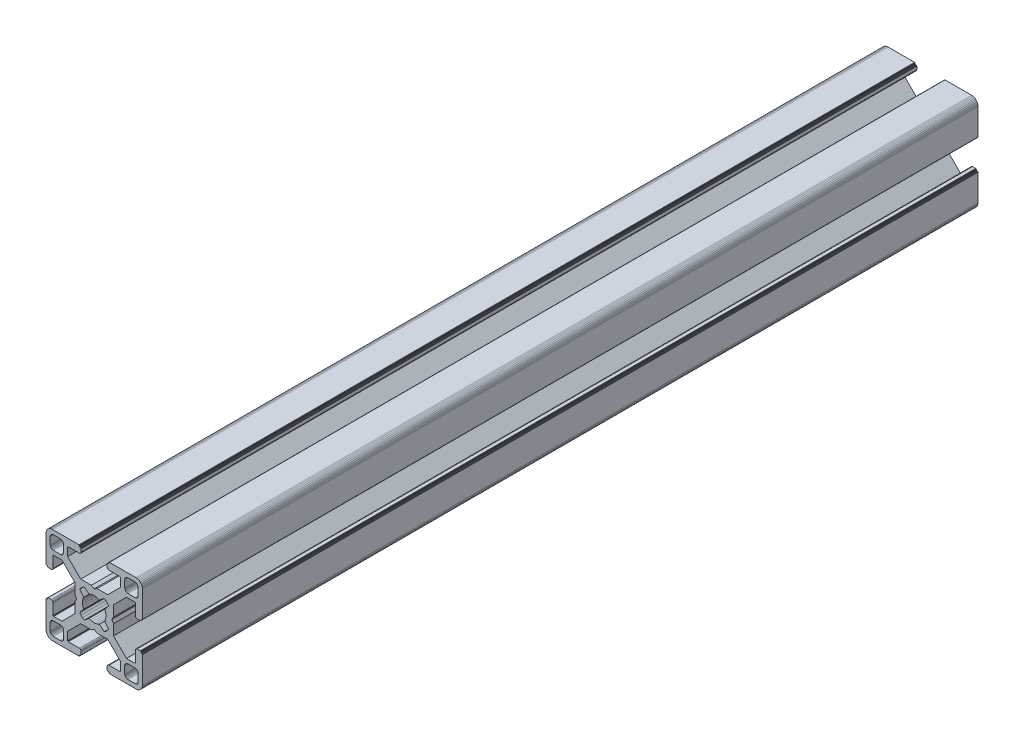
from build123d import *

# Parameters (mm, degrees)
BOSS_EXTRUDE1_DEPTH = 260


with BuildPart() as part:
    # Sketch1 → Boss-Extrude1 (new body)
    with BuildSketch(Plane.XY):
        Polygon((28.34729664, 29.969613999), (28.000000864, 29.999999329), (19.750000909, 29.999999329), (19.715268165, 29.996961355), (19.681595266, 29.987938702), (19.649999216, 29.973205179), (19.621443003, 29.953207821), (19.596790895, 29.928557575), (19.576793537, 29.899999499), (19.562061876, 29.868405312), (19.55303736, 29.834728688), (19.549999386, 29.799999669), (19.549999386, 29.699999839), (19.546961412, 29.665268958), (19.537936896, 29.631596059), (19.523203373, 29.599998146), (19.503207877, 29.571441934), (19.478557631, 29.546789825), (19.449999556, 29.526794329), (19.418403506, 29.512060806), (19.384728745, 29.503038153), (19.349999726, 29.500000179), (19.249999896, 29.500000179), (19.215267517, 29.496958527), (19.181592755, 29.487935874), (19.149996706, 29.47320235), (19.12143863, 29.453206855), (19.096788384, 29.428554746), (19.076791026, 29.399996671), (19.062057503, 29.368402484), (19.05303485, 29.334725859), (19.049996876, 29.299998703), (19.049996876, 28.39999837), (19.059110798, 28.29580945), (19.08618062, 28.194785165), (19.13038119, 28.099997016), (19.190369539, 28.014324653), (19.264324002, 27.94037019), (19.349996366, 27.88038184), (19.444784515, 27.836181271), (19.545806937, 27.809111449), (19.650010894, 27.799984574), (23.050010706, 27.799984574), (23.084741588, 27.7969466), (23.118414487, 27.787923946), (23.150012399, 27.773190423), (23.178568612, 27.753193065), (23.203220721, 27.728542819), (23.223218079, 27.699984744), (23.237949739, 27.668386831), (23.246974255, 27.634713932), (23.25001142, 27.59998608), (23.25001142, 25.049987618), (19.204474482, 20.999982084), (15.900007876, 20.999982084), (15.000008474, 20.48483404), (14.10000814, 20.999982084), (10.795543398, 20.999982084), (7.997342887, 23.801274731), (6.750011387, 25.049984589), (6.750011387, 27.599983051), (6.753049362, 27.634713932), (6.762072946, 27.668386831), (6.776805538, 27.699984744), (6.796801965, 27.728542819), (6.821454073, 27.753193065), (6.850011218, 27.773190423), (6.881607267, 27.787923946), (6.915282029, 27.7969466), (6.950011048, 27.799984574), (10.350011791, 27.799984574), (10.45420071, 27.809098497), (10.555223133, 27.836168318), (10.650011282, 27.880368888), (10.735683645, 27.940357238), (10.809638108, 28.014311701), (10.869626458, 28.099984064), (10.913827027, 28.194772213), (10.940895918, 28.295796498), (10.950010772, 28.399985417), (10.950010772, 29.299985751), (10.946974575, 29.334739239), (10.93795065, 29.368415522), (10.923215933, 29.400009153), (10.903218427, 29.428566473), (10.878566319, 29.45321765), (10.849999264, 29.473204166), (10.818403214, 29.487937689), (10.784728453, 29.496960342), (10.749999434, 29.500000179), (10.649999604, 29.500000179), (10.615270585, 29.503038153), (10.581595823, 29.512060806), (10.549999774, 29.526794329), (10.521441698, 29.546789825), (10.496791452, 29.571441934), (10.476795025, 29.599998146), (10.462061502, 29.631596059), (10.453037918, 29.665268958), (10.449999943, 29.699999839), (10.449999943, 29.799999669), (10.446961969, 29.834728688), (10.437938385, 29.868405312), (10.423205793, 29.899999499), (10.403208435, 29.928557575), (10.378557257, 29.953207821), (10.350000113, 29.973205179), (10.318404064, 29.987938702), (10.284729302, 29.996961355), (10.250000283, 29.999999329), (1.999999397, 29.999999329), (1.652702689, 29.969613999), (1.315958682, 29.879383743), (0.999999233, 29.732050374), (0.714424066, 29.532089829), (0.467910431, 29.285576195), (0.267948955, 28.999999166), (0.120614655, 28.684040532), (0.030384399, 28.34729664), (0, 28.000000864), (0, 19.750000909), (0.003037974, 19.715268165), (0.012061559, 19.681595266), (0.026795082, 19.649999216), (0.046790577, 19.621441141), (0.071442686, 19.596789032), (0.09999983, 19.576793537), (0.13159588, 19.562060013), (0.165270641, 19.55303736), (0.19999966, 19.549999386), (0.299999461, 19.549999386), (0.334728509, 19.546959549), (0.368403242, 19.537936896), (0.399999321, 19.523203373), (0.428556465, 19.503207877), (0.453208573, 19.478555769), (0.473204069, 19.449997693), (0.487937592, 19.418403506), (0.496961176, 19.384728745), (0.499999151, 19.349999726), (0.499999151, 19.249998033), (0.503038056, 19.215269014), (0.512060709, 19.181594253), (0.526794232, 19.150000066), (0.546790194, 19.121441524), (0.571441837, 19.096789882), (0.60000029, 19.076794925), (0.631595686, 19.062061999), (0.665270619, 19.053039982), (0.700000626, 19.050000801), (1.60000096, 19.050000801), (1.704189879, 19.059116587), (1.805213233, 19.086186409), (1.90000045, 19.130385115), (1.985673745, 19.190375328), (2.059627277, 19.264327928), (2.119616325, 19.350002154), (2.163816196, 19.444788441), (2.190886018, 19.545812726), (2.200000872, 19.650001645), (2.200000872, 23.050001457), (2.203039777, 23.084732338), (2.212062431, 23.118405237), (2.226795954, 23.15000315), (2.246792381, 23.178559362), (2.271443558, 23.203211471), (2.300000702, 23.223206967), (2.331596752, 23.23794049), (2.365271513, 23.246965006), (2.400001464, 23.250001117), (4.950000857, 23.250001117), (7.997332093, 20.202670812), (8.995535423, 19.204467788), (8.995535423, 15.900001182), (9.515148227, 15.00000178), (8.995535423, 14.100002378), (8.995535423, 10.795536704), (4.950000857, 6.750002138), (2.400001464, 6.750002138), (2.365271513, 6.753040112), (2.331596752, 6.762063697), (2.300000702, 6.77679722), (2.271443558, 6.796793647), (2.246792381, 6.821444824), (2.226795954, 6.850001968), (2.212062431, 6.881598018), (2.203039777, 6.915272779), (2.200000872, 6.950002729), (2.200000872, 10.350002542), (2.190896812, 10.454174265), (2.16382699, 10.555197618), (2.119627119, 10.649984836), (2.059638071, 10.735658131), (1.985684539, 10.809611663), (1.900011244, 10.869600944), (1.805224027, 10.913800582), (1.704200673, 10.940870404), (1.600011754, 10.949986189), (0.70001142, 10.949986189), (0.665281355, 10.946948596), (0.631606253, 10.937926283), (0.600010578, 10.923193954), (0.571451747, 10.903199537), (0.546799638, 10.87854836), (0.526794232, 10.850000195), (0.512060709, 10.818404146), (0.503038056, 10.784730315), (0.499999151, 10.750000365), (0.499999151, 10.650000535), (0.496961176, 10.615270585), (0.487937592, 10.581596754), (0.473204069, 10.550000705), (0.453208573, 10.521443561), (0.428556465, 10.496791452), (0.399999321, 10.476795956), (0.368403242, 10.462062433), (0.334728509, 10.453038849), (0.299999461, 10.449999943), (0.19999966, 10.449999943), (0.165270641, 10.446961969), (0.13159588, 10.437939316), (0.09999983, 10.423205793), (0.071442686, 10.403209366), (0.046790577, 10.378558189), (0.026795082, 10.350000113), (0.012061559, 10.318404064), (0.003037974, 10.284729302), (0, 10.250000283), (0, 1.999999397), (0.030384399, 1.652702689), (0.120614655, 1.315958682), (0.267948955, 0.999999233), (0.467910431, 0.714424066), (0.714424066, 0.467910431), (0.999999233, 0.267948955), (1.315958682, 0.120614655), (1.652702689, 0.030384399), (1.999999397, 0), (10.250000283, 0), (10.284729302, 0.003037974), (10.318404064, 0.012061559), (10.350000113, 0.026795082), (10.378557257, 0.046790577), (10.403208435, 0.071442686), (10.423205793, 0.09999983), (10.437938385, 0.13159588), (10.446961969, 0.165270641), (10.449999943, 0.19999966), (10.449999943, 0.300000422), (10.453037918, 0.334729441), (10.462061502, 0.368404202), (10.476795025, 0.400000252), (10.496791452, 0.428557396), (10.521441698, 0.453208573), (10.549999774, 0.473205), (10.581595823, 0.487938523), (10.615270585, 0.496961176), (10.649999604, 0.500000082), (10.749999434, 0.500000082), (10.784728453, 0.503038056), (10.818403214, 0.512060709), (10.849999264, 0.526794232), (10.878547894, 0.546800104), (10.903198606, 0.571451747), (10.923194493, 0.6000102), (10.93792742, 0.631606528), (10.946949437, 0.66528146), (10.950010772, 0.699984975), (10.950010772, 1.599985308), (10.940895918, 1.704174228), (10.913827027, 1.805197581), (10.869626458, 1.89998573), (10.809638108, 1.985658094), (10.735683645, 2.059612557), (10.650011282, 2.119600674), (10.555223133, 2.163801476), (10.45420071, 2.190870367), (10.350011791, 2.199985221), (6.950011048, 2.199985221), (6.915282029, 2.203024126), (6.881607267, 2.212046779), (6.850011218, 2.226780302), (6.821454073, 2.246776729), (6.796801965, 2.271427907), (6.776805538, 2.299985982), (6.762072946, 2.331582032), (6.753049362, 2.365256793), (6.750011387, 2.399985812), (6.750011387, 4.949985206), (9.787457566, 7.990785077), (10.795545277, 8.999985833), (14.100010019, 8.999985833), (15.000010353, 9.515133877), (15.900009756, 8.999985833), (19.204476361, 8.999985833), (20.21256413, 7.990786065), (23.25001142, 4.949988235), (23.25001142, 2.399988841), (23.246974255, 2.365256793), (23.237949739, 2.331582032), (23.223218079, 2.299985982), (23.203220721, 2.271427907), (23.178568612, 2.246776729), (23.150012399, 2.226780302), (23.118414487, 2.212046779), (23.084741588, 2.203024126), (23.050010706, 2.199985221), (19.650010894, 2.199985221), (19.545806937, 2.190883319), (19.444784515, 2.163814428), (19.349996366, 2.119613626), (19.264324002, 2.059625509), (19.190369539, 1.985671046), (19.13038119, 1.899998682), (19.08618062, 1.805210533), (19.059110798, 1.70418718), (19.049996876, 1.599998261), (19.049996876, 0.699997927), (19.053035506, 0.665268966), (19.062058795, 0.631594374), (19.076792915, 0.599998603), (19.096790813, 0.571440905), (19.121441524, 0.546790194), (19.149999978, 0.526794306), (19.181596306, 0.51206138), (19.215271238, 0.503039363), (19.249999896, 0.500000082), (19.349999726, 0.500000082), (19.384728745, 0.496961176), (19.418403506, 0.487938523), (19.449999556, 0.473205), (19.478557631, 0.453208573), (19.503207877, 0.428557396), (19.523203373, 0.400000252), (19.537936896, 0.368404202), (19.546961412, 0.334729441), (19.549999386, 0.300000422), (19.549999386, 0.19999966), (19.55303736, 0.165270641), (19.562061876, 0.13159588), (19.576793537, 0.09999983), (19.596789964, 0.071441755), (19.621442072, 0.046789646), (19.649998285, 0.02679415), (19.681594335, 0.012060627), (19.715267234, 0.003037043), (19.750000909, 0), (28.000000864, 0), (28.34729664, 0.030384399), (28.684040532, 0.120614655), (28.999999166, 0.267948955), (29.285576195, 0.467910431), (29.532089829, 0.714424066), (29.732050374, 0.999999233), (29.879383743, 1.315958682), (29.969613999, 1.652702689), (29.999999329, 1.999999397), (29.999999329, 10.250000283), (29.996974806, 10.284715361), (29.987951516, 10.318389952), (29.973217396, 10.349985723), (29.953219499, 10.378543421), (29.928568787, 10.403194133), (29.899999499, 10.423205793), (29.868405312, 10.437939316), (29.834728688, 10.446961969), (29.799999669, 10.449999943), (29.699999839, 10.449999943), (29.664909937, 10.453400043), (29.631233313, 10.462423628), (29.599637263, 10.477157151), (29.57108105, 10.497152646), (29.546427079, 10.521804755), (29.526433446, 10.550361899), (29.511699923, 10.581957949), (29.502675407, 10.615631779), (29.499637433, 10.650361729), (29.499637433, 10.750361559), (29.49697202, 10.784715548), (29.487949367, 10.818389378), (29.473215844, 10.849985428), (29.453220348, 10.878542572), (29.428568239, 10.90319468), (29.400010164, 10.923190176), (29.368415977, 10.937923699), (29.334741215, 10.946947284), (29.300012197, 10.949986189), (28.400011863, 10.949986189), (28.29581215, 10.9408876), (28.194787865, 10.913817778), (28.099999716, 10.86961814), (28.014327352, 10.809628859), (27.940374752, 10.735675327), (27.880384539, 10.650002032), (27.836185833, 10.555214814), (27.809114148, 10.454191461), (27.800000225, 10.350002542), (27.800000225, 6.950002729), (27.796962251, 6.915272779), (27.787939598, 6.881598018), (27.773206075, 6.850001968), (27.753208716, 6.821444824), (27.728558471, 6.796793647), (27.700000395, 6.77679722), (27.668404345, 6.762063697), (27.634729584, 6.753040112), (27.599998702, 6.750002138), (25.05000024, 6.750002138), (23.809199132, 7.99080223), (21.004464477, 10.795534588), (21.004464477, 14.100000262), (20.484851673, 14.999999665), (21.004464477, 15.899999067), (21.004464477, 19.204465672), (25.05000024, 23.250001117), (27.599998702, 23.250001117), (27.634729584, 23.246965006), (27.668404345, 23.23794049), (27.700000395, 23.223206967), (27.728558471, 23.203211471), (27.753208716, 23.178559362), (27.773206075, 23.15000315), (27.787939598, 23.118405237), (27.796962251, 23.084732338), (27.800000225, 23.050001457), (27.800000225, 19.650001645), (27.809114148, 19.545812726), (27.836185833, 19.444788441), (27.880384539, 19.350002154), (27.940370508, 19.264323684), (28.014323108, 19.190371084), (28.099995472, 19.130380872), (28.194783621, 19.086182165), (28.295807906, 19.059112343), (28.400001069, 19.050000801), (29.300001402, 19.050000801), (29.334730421, 19.053040638), (29.368405183, 19.062063291), (29.39999937, 19.076796814), (29.42819671, 19.097149726), (29.452848353, 19.1218023), (29.472843309, 19.150360754), (29.487576235, 19.181955219), (29.496598252, 19.215630151), (29.499637433, 19.250359227), (29.499637433, 19.35036092), (29.502675407, 19.385089939), (29.511699923, 19.4187647), (29.526433446, 19.450358887), (29.546427079, 19.478916963), (29.57108105, 19.503569071), (29.599637263, 19.523564567), (29.631233313, 19.53829809), (29.664909937, 19.547320743), (29.699999839, 19.549999386), (29.799999669, 19.549999386), (29.834728688, 19.55303736), (29.868405312, 19.562060013), (29.899999499, 19.576793537), (29.928557575, 19.596789032), (29.953207821, 19.621441141), (29.973205179, 19.649999216), (29.987938702, 19.681595266), (29.996961355, 19.715268165), (29.999999329, 19.750000909), (29.999999329, 28.000000864), (29.969613999, 28.34729664), (29.879383743, 28.684040532), (29.732050374, 28.999999166), (29.532089829, 29.285576195), (29.285576195, 29.532089829), (28.999999166, 29.732050374), (28.684040532, 29.879383743), align=None)
        Polygon((1.299998723, 25.499999523), (1.299998723, 27.699999511), (1.312309876, 27.856435627), (1.348942518, 28.009016067), (1.408992335, 28.153989464), (1.490981318, 28.287785128), (1.592892222, 28.407108039), (1.71221327, 28.50901708), (1.846008119, 28.591006994), (1.9909814, 28.651056811), (2.143563703, 28.687689453), (2.299998887, 28.699999675), (4.499998875, 28.699999675), (4.656434059, 28.687689453), (4.809016362, 28.651056811), (4.953989759, 28.591006994), (5.087784491, 28.50901708), (5.207106471, 28.407108039), (5.309016444, 28.287785128), (5.391005427, 28.153989464), (5.451056175, 28.009016067), (5.487687886, 27.856435627), (5.499999039, 27.699999511), (5.499999039, 25.499999523), (5.487687886, 25.34356527), (5.451056175, 25.190982968), (5.391005427, 25.04600957), (5.309016444, 24.912213907), (5.207106471, 24.792892858), (5.087784491, 24.690981954), (4.953989759, 24.60899204), (4.809016362, 24.548944086), (4.656434059, 24.512309581), (4.499998875, 24.499999359), (2.299998887, 24.499999359), (2.143563703, 24.512309581), (1.9909814, 24.548944086), (1.846008119, 24.60899204), (1.71221327, 24.690981954), (1.592892222, 24.792892858), (1.490981318, 24.912213907), (1.408992335, 25.04600957), (1.348942518, 25.190982968), (1.312309876, 25.34356527), align=None, mode=Mode.SUBTRACT)
        Polygon((25.34356527, 28.687689453), (25.499999523, 28.699999675), (27.699999511, 28.699999675), (27.856435627, 28.687689453), (28.009017929, 28.651056811), (28.153991327, 28.591006994), (28.28778699, 28.50901708), (28.407108039, 28.407108039), (28.50901708, 28.287785128), (28.591006994, 28.153989464), (28.651056811, 28.009016067), (28.687689453, 27.856435627), (28.700001538, 27.699999511), (28.700001538, 25.499999523), (28.687689453, 25.34356527), (28.651056811, 25.190982968), (28.591006994, 25.04600957), (28.50901708, 24.912213907), (28.407108039, 24.792892858), (28.28778699, 24.690981954), (28.153991327, 24.60899204), (28.009017929, 24.548944086), (27.856435627, 24.512309581), (27.699999511, 24.499999359), (25.499999523, 24.499999359), (25.34356527, 24.512309581), (25.190982968, 24.548944086), (25.04600957, 24.60899204), (24.912215769, 24.690981954), (24.792892858, 24.792892858), (24.690981954, 24.912213907), (24.608993903, 25.04600957), (24.548944086, 25.190982968), (24.512311444, 25.34356527), (24.500001222, 25.499999523), (24.500001222, 27.699999511), (24.512311444, 27.856435627), (24.548944086, 28.009016067), (24.608993903, 28.153989464), (24.690981954, 28.287785128), (24.792892858, 28.407108039), (24.912215769, 28.50901708), (25.04600957, 28.591006994), (25.190982968, 28.651056811), align=None, mode=Mode.SUBTRACT)
        Polygon((14.999999665, 18.649999052), (15.550030395, 18.608318642), (16.087498516, 18.484227359), (16.600128263, 18.280562013), (18.13592948, 19.518401474), (18.644984812, 19.11874488), (19.103571773, 18.662061542), (19.505336881, 18.154669553), (18.280562013, 16.600130126), (18.484227359, 16.087498516), (18.608318642, 15.550030395), (18.649999052, 14.999999665), (18.608318642, 14.449968934), (18.484227359, 13.912500814), (18.280562013, 13.399870135), (19.505336881, 11.845329776), (19.103571773, 11.337937787), (18.644984812, 10.881252587), (18.13592948, 10.481598787), (16.600128263, 11.719437316), (16.087498516, 11.515771039), (15.550030395, 11.391680688), (14.999999665, 11.349999346), (14.449968934, 11.391680688), (13.912500814, 11.515771039), (13.399870135, 11.719437316), (11.864069849, 10.481598787), (11.355013587, 10.881252587), (10.896427557, 11.337937787), (10.494662449, 11.845329776), (11.719438247, 13.399870135), (11.515771039, 13.912500814), (11.391680688, 14.449968934), (11.349999346, 14.999999665), (11.391680688, 15.550030395), (11.515771039, 16.087498516), (11.719438247, 16.600130126), (10.494662449, 18.154669553), (10.896427557, 18.662061542), (11.355013587, 19.11874488), (11.864069849, 19.518401474), (13.399870135, 18.280562013), (13.912500814, 18.484227359), (14.449968934, 18.608318642), align=None, mode=Mode.SUBTRACT)
        Polygon((4.499998875, 1.299999771), (2.299998887, 1.299999771), (2.143563703, 1.312310807), (1.9909814, 1.348942518), (1.846008119, 1.408992335), (1.71221327, 1.490982249), (1.592892222, 1.592892222), (1.490981318, 1.712214202), (1.408992335, 1.846008934), (1.348942518, 1.990982331), (1.312309876, 2.143564634), (1.299998723, 2.299998887), (1.299998723, 4.499999806), (1.312309876, 4.656434059), (1.348942518, 4.809017293), (1.408992335, 4.95399069), (1.490981318, 5.087785423), (1.592892222, 5.207106471), (1.71221327, 5.309017375), (1.846008119, 5.391006358), (1.9909814, 5.451056175), (2.143563703, 5.487688817), (2.299998887, 5.49999997), (4.499998875, 5.49999997), (4.656434059, 5.487688817), (4.809016362, 5.451056175), (4.953989759, 5.391006358), (5.087784491, 5.309017375), (5.207106471, 5.207106471), (5.309016444, 5.087785423), (5.391005427, 4.95399069), (5.451056175, 4.809017293), (5.487687886, 4.656434059), (5.499999039, 4.499999806), (5.499999039, 2.299998887), (5.487687886, 2.143564634), (5.451056175, 1.990982331), (5.391005427, 1.846008934), (5.309016444, 1.712214202), (5.207106471, 1.592892222), (5.087784491, 1.490982249), (4.953989759, 1.408992335), (4.809016362, 1.348942518), (4.656434059, 1.312310807), align=None, mode=Mode.SUBTRACT)
        Polygon((27.699999511, 1.299999771), (25.499999523, 1.299999771), (25.34356527, 1.312310807), (25.190982968, 1.348942518), (25.04600957, 1.408992335), (24.912215769, 1.490982249), (24.792892858, 1.592892222), (24.690981954, 1.712214202), (24.608993903, 1.846008934), (24.548944086, 1.990982331), (24.512311444, 2.143564634), (24.500001222, 2.299998887), (24.500001222, 4.499999806), (24.512311444, 4.656434059), (24.548944086, 4.809017293), (24.608993903, 4.95399069), (24.690981954, 5.087785423), (24.792892858, 5.207106471), (24.912215769, 5.309017375), (25.04600957, 5.391006358), (25.190982968, 5.451056175), (25.34356527, 5.487688817), (25.499999523, 5.49999997), (27.699999511, 5.49999997), (27.856435627, 5.487688817), (28.009017929, 5.451056175), (28.153991327, 5.391006358), (28.28778699, 5.309017375), (28.407108039, 5.207106471), (28.50901708, 5.087785423), (28.591006994, 4.95399069), (28.651056811, 4.809017293), (28.687689453, 4.656434059), (28.700001538, 4.499999806), (28.700001538, 2.299998887), (28.687689453, 2.143564634), (28.651056811, 1.990982331), (28.591006994, 1.846008934), (28.50901708, 1.712214202), (28.407108039, 1.592892222), (28.28778699, 1.490982249), (28.153991327, 1.408992335), (28.009017929, 1.348942518), (27.856435627, 1.312310807), align=None, mode=Mode.SUBTRACT)
    extrude(amount=-BOSS_EXTRUDE1_DEPTH)


solid = part.part
